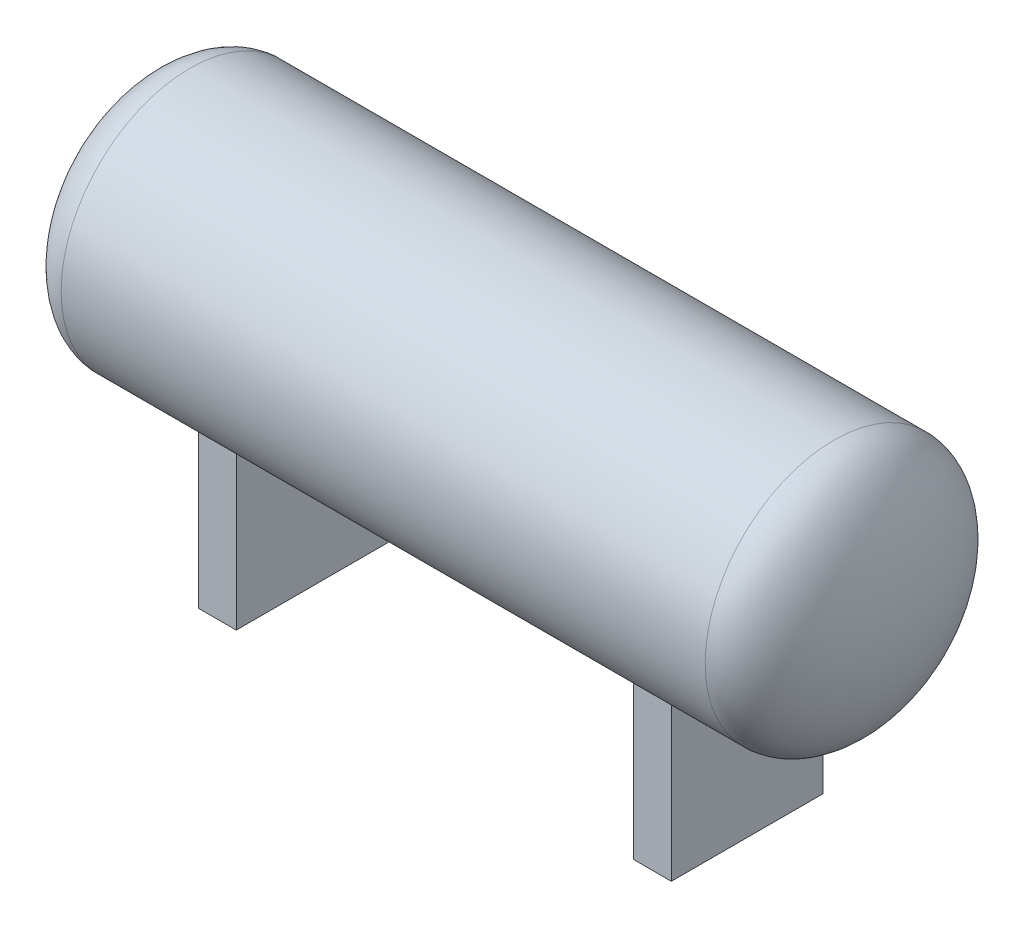
from build123d import *

# Parameters (mm, degrees)
SKETCH1_W         = 10000
SKETCH1_H         = 2000
DOME1_FACE_RADIUS = 2000
DOME1_HEIGHT      = 1000
DOME2_FACE_RADIUS = 2000
DOME2_HEIGHT      = 1000
SKETCH2_W         = 585.663948454
SKETCH2_H         = 2352.753448103
EXTRUDE1_DEPTH    = 4000


with BuildPart() as part:
    # Sketch1 → Revolve1 (revolve)
    with BuildSketch(Plane.XY, mode=Mode.PRIVATE) as revolve1_sk:
        with Locations((0, 1000)):
            Rectangle(SKETCH1_W, SKETCH1_H)
    revolve(revolve1_sk.sketch.rotate(Axis((-4927.316655316, 0, 0), (1, 0, 0)), 180), axis=Axis((-4927.316655316, 0, 0), (1, 0, 0)))

    # Dome1: an elliptical dome of height H over a round flat face of radius A is half a spheroid: the quarter ellipse of half axes A and H revolved about the face's axis
    with BuildSketch(Plane((5000, 0, 0), x_dir=(0, 0, 1), z_dir=(0, 1, 0)), mode=Mode.PRIVATE) as dome1_quarter:
        Ellipse(DOME1_FACE_RADIUS, DOME1_HEIGHT)
        Rectangle(DOME1_FACE_RADIUS, DOME1_HEIGHT, align=(Align.MIN, Align.MIN), mode=Mode.INTERSECT)
    revolve(dome1_quarter.sketch, axis=Axis((5000, 0, 0), (1, 0, 0)))

    # Dome2: an elliptical dome of height H over a round flat face of radius A is half a spheroid: the quarter ellipse of half axes A and H revolved about the face's axis
    with BuildSketch(Plane((-5000, 0, 0), x_dir=(0, 0, -1), z_dir=(0, 1, 0)), mode=Mode.PRIVATE) as dome2_quarter:
        Ellipse(DOME2_FACE_RADIUS, DOME2_HEIGHT)
        Rectangle(DOME2_FACE_RADIUS, DOME2_HEIGHT, align=(Align.MIN, Align.MIN), mode=Mode.INTERSECT)
    revolve(dome2_quarter.sketch, axis=Axis((-5000, 0, 0), (-1, 0, 0)))

    # Sketch2 → Extrude1 (add)
    with BuildSketch(Plane(origin=(0, 0, 0), x_dir=(1, 0, 0), z_dir=(0, 1, 0))):
        with Locations((-3377.665357898, -20.195308567)):
            Rectangle(SKETCH2_W, SKETCH2_H)
        with Locations((3377.665357898, -20.195308567)):
            Rectangle(SKETCH2_W, SKETCH2_H)
    extrude(amount=-EXTRUDE1_DEPTH)


solid = part.part
